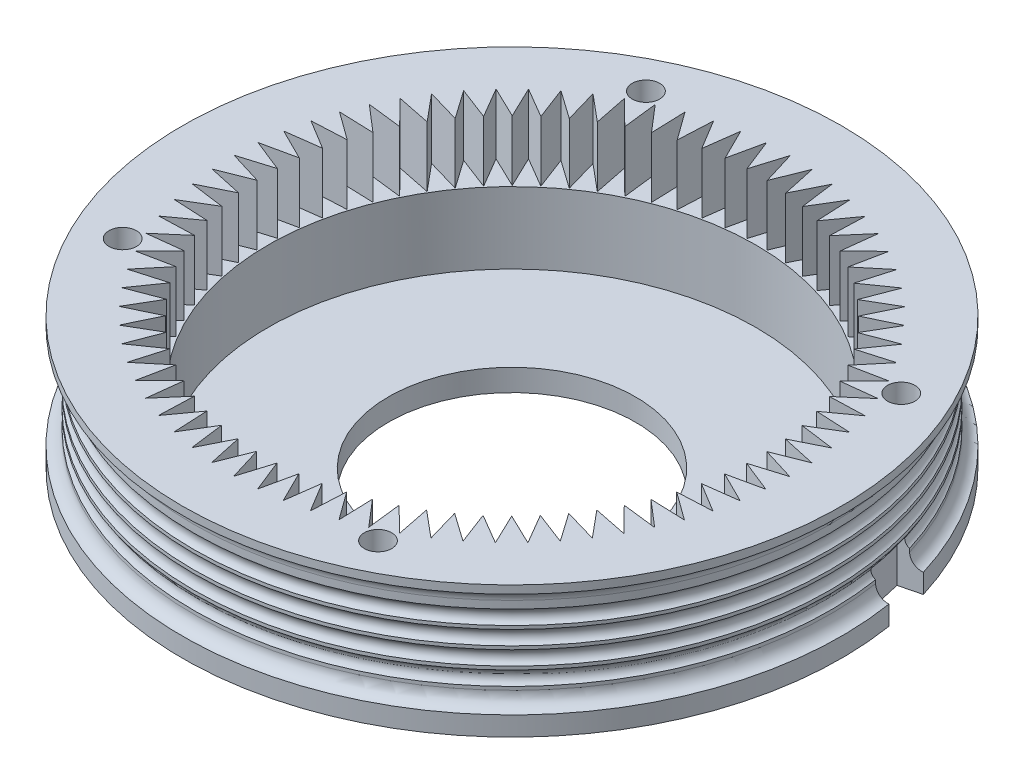
from build123d import *

# Parameters (mm, degrees)
SKETCH1_R           = 23
BOSS_EXTRUDE1_DEPTH = 2
SKETCH2_R           = 30
SKETCH2_R_2         = 22.2
BOSS_EXTRUDE2_DEPTH = 12
SKETCH3_R           = 11.25
CUT_EXTRUDE1_DEPTH  = 10
CUT_EXTRUDE8_DEPTH  = 5.5
SKETCH5_R           = 1.25
CUT_EXTRUDE3_DEPTH  = 45.676615807
SKETCH8_R           = 2.5
CUT_EXTRUDE5_DEPTH  = 2
BOSS_EXTRUDE3_DEPTH = 3
CUT_EXTRUDE9_START  = -3
SKETCH13_R          = 3.5
CUT_EXTRUDE9_DEPTH  = 3
CUT_EXTRUDE10_DEPTH = 4


with BuildPart() as part:
    # Sketch1 → Boss-Extrude1 (new body)
    with BuildSketch(Plane(origin=(0, 0, 0), x_dir=(1, 0, 0), z_dir=(0, 1, 0))):
        Circle(SKETCH1_R)
    extrude(amount=-BOSS_EXTRUDE1_DEPTH)

    # Sketch2 → Boss-Extrude2 (add)
    with BuildSketch(Plane(origin=(0, 0, 0), x_dir=(1, 0, 0), z_dir=(0, 1, 0))):
        Circle(SKETCH2_R)
        Circle(SKETCH2_R_2, mode=Mode.SUBTRACT)
    extrude(amount=BOSS_EXTRUDE2_DEPTH)

    # Sketch3 → Cut-Extrude1 (cut)
    with BuildSketch(Plane(origin=(0, 0, 0), x_dir=(1, 0, 0), z_dir=(0, 1, 0))):
        Circle(SKETCH3_R)
    extrude(amount=-CUT_EXTRUDE1_DEPTH, mode=Mode.SUBTRACT)

    # Sketch10 → Cut-Extrude8 (cut)
    with BuildSketch(Plane(origin=(0, 12, 0), x_dir=(1, 0, 0), z_dir=(0, 1, 0))):
        Polygon((8.200315972, -23.949003355), (8.095646912, -20.796423541), (10.150000757, -23.190028641), (9.785351218, -20.056859988), (12.030350745, -22.272642516), (11.408211652, -19.180287743), (13.828521239, -21.20311166), (12.953142433, -18.172694685), (15.532228911, -19.988742051), (14.409590117, -17.040963696), (17.12983571, -18.637829065), (15.76760569, -15.792825644), (18.610428362, -17.159600809), (17.017912527, -14.43680658), (19.963892917, -15.564155079), (18.151969766, -12.982169489), (21.18098384, -13.862390389), (19.162030646, -11.438851016), (22.253387167, -12.065931515), (20.041195426, -9.817393592), (23.173777294, -10.187050095), (20.78345852, -8.128873414), (23.935867025, -8.238580793), (21.383749518, -6.384824789), (24.534450513, -6.233833631), (21.837967824, -4.597161336), (24.965438827, -4.186503063), (22.143010666, -2.77809461), (25.225887879, -2.110574435), (22.296794293, -0.940050681), (25.314018538, -0.020228443), (22.298268206, 0.904414747), (25.229228782, 2.070255729), (22.147422337, 2.742702106), (24.972097812, 4.146597956), (21.845287117, 4.562254028), (24.544382092, 6.194614714), (21.393926434, 6.350641129), (23.949003355, 8.200315972), (20.796423541, 8.095646912), (23.190028641, 10.150000757), (20.056859988, 9.785351218), (22.272642516, 12.030350745), (19.180287743, 11.408211652), (21.20311166, 13.828521239), (18.172694685, 12.953142433), (19.988742051, 15.532228911), (17.040963696, 14.409590117), (18.637829065, 17.12983571), (15.792825644, 15.76760569), (17.159600809, 18.610428362), (14.43680658, 17.017912527), (15.564155079, 19.963892917), (12.982169489, 18.151969766), (13.862390389, 21.18098384), (11.438851016, 19.162030646), (12.065931515, 22.253387167), (9.817393592, 20.041195426), (10.187050095, 23.173777294), (8.128873414, 20.78345852), (8.238580793, 23.935867025), (6.384824789, 21.383749518), (6.233833631, 24.534450513), (4.597161336, 21.837967824), (4.186503063, 24.965438827), (2.77809461, 22.143010666), (2.110574435, 25.225887879), (0.940050681, 22.296794293), (0.020228443, 25.314018538), (-0.904414747, 22.298268206), (-2.070255729, 25.229228782), (-2.742702106, 22.147422337), (-4.146597956, 24.972097812), (-4.562254028, 21.845287117), (-6.194614714, 24.544382092), (-6.350641129, 21.393926434), (-8.200315972, 23.949003355), (-8.095646912, 20.796423541), (-10.150000757, 23.190028641), (-9.785351218, 20.056859988), (-12.030350745, 22.272642516), (-11.408211652, 19.180287743), (-13.828521239, 21.20311166), (-12.953142433, 18.172694685), (-15.532228911, 19.988742051), (-14.409590117, 17.040963696), (-17.12983571, 18.637829065), (-15.76760569, 15.792825644), (-18.610428362, 17.159600809), (-17.017912527, 14.43680658), (-19.963892917, 15.564155079), (-18.151969766, 12.982169489), (-21.18098384, 13.862390389), (-19.162030646, 11.438851016), (-22.253387167, 12.065931515), (-20.041195426, 9.817393592), (-23.173777294, 10.187050095), (-20.78345852, 8.128873414), (-23.935867025, 8.238580793), (-21.383749518, 6.384824789), (-24.534450513, 6.233833631), (-21.837967824, 4.597161336), (-24.965438827, 4.186503063), (-22.143010666, 2.77809461), (-25.225887879, 2.110574435), (-22.296794293, 0.940050681), (-25.314018538, 0.020228443), (-22.298268206, -0.904414747), (-25.229228782, -2.070255729), (-22.147422337, -2.742702106), (-24.972097812, -4.146597956), (-21.845287117, -4.562254028), (-24.544382092, -6.194614714), (-21.393926434, -6.350641129), (-23.949003355, -8.200315972), (-20.796423541, -8.095646912), (-23.190028641, -10.150000757), (-20.056859988, -9.785351218), (-22.272642516, -12.030350745), (-19.180287743, -11.408211652), (-21.20311166, -13.828521239), (-18.172694685, -12.953142433), (-19.988742051, -15.532228911), (-17.040963696, -14.409590118), (-18.637829065, -17.12983571), (-15.792825644, -15.76760569), (-17.159600809, -18.610428362), (-14.43680658, -17.017912527), (-15.564155079, -19.963892917), (-12.982169489, -18.151969766), (-13.862390389, -21.18098384), (-11.438851016, -19.162030646), (-12.065931515, -22.253387167), (-9.817393592, -20.041195426), (-10.187050095, -23.173777294), (-8.128873414, -20.78345852), (-8.238580793, -23.935867025), (-6.384824789, -21.383749518), (-6.233833631, -24.534450513), (-4.597161336, -21.837967824), (-4.186503063, -24.965438827), (-2.77809461, -22.143010666), (-2.110574435, -25.225887879), (-0.940050681, -22.296794293), (-0.020228443, -25.314018538), (0.904414747, -22.298268206), (2.070255729, -25.229228782), (2.742702106, -22.147422337), (4.146597956, -24.972097812), (4.562254028, -21.845287117), (6.194614714, -24.544382092), (6.350641129, -21.393926434), align=None)
    extrude(amount=-CUT_EXTRUDE8_DEPTH, mode=Mode.SUBTRACT)

    # Sketch5 → Cut-Extrude3 (cut, through all)
    with BuildSketch(Plane(origin=(0, 12, 0), x_dir=(1, 0, 0), z_dir=(0, 1, 0))):
        with Locations((23.816653914, 11.619681422)):
            Circle(SKETCH5_R)
        with Locations((11.619681422, -23.816653914)):
            Circle(SKETCH5_R)
        with Locations((-23.816653914, -11.619681422)):
            Circle(SKETCH5_R)
        with Locations((-11.619681422, 23.816653914)):
            Circle(SKETCH5_R)
    extrude(amount=-CUT_EXTRUDE3_DEPTH, mode=Mode.SUBTRACT)

    # Sketch8 → Cut-Extrude5 (cut)
    with BuildSketch(Plane(origin=(0, 0, 0), x_dir=(-1, 0, 0), z_dir=(0, -1, 0))):
        with Locations((-23.816653914, 11.619681422)):
            Circle(SKETCH8_R)
        with Locations((11.619681422, 23.816653914)):
            Circle(SKETCH8_R)
        with Locations((23.816653914, -11.619681422)):
            Circle(SKETCH8_R)
        with Locations((-11.619681422, -23.816653914)):
            Circle(SKETCH8_R)
    extrude(amount=-CUT_EXTRUDE5_DEPTH, mode=Mode.SUBTRACT)

    # Sketch6 → Cut-Revolve1 (revolve, cut)
    with BuildSketch(Plane(origin=(0, 0, 0), x_dir=(0, 0, -1), z_dir=(1, 0, 0))):
        with BuildLine():
            Line((30.052591235, 11.269978745), (30.611201465, 11.269978745))
            Line((30.611201465, 11.269978745), (30.611201465, 1.744054661))
            Line((30.611201465, 1.744054661), (30.052591235, 1.744054661))
            ThreePointArc((30.052591235, 1.744054661), (29.280418603, 2.14822719), (28.97105922, 2.963029485))
            Line((28.97105922, 2.963029485), (28.97105922, 3.270113549))
            ThreePointArc((28.97105922, 3.270113549), (28.601311894, 3.916571517), (28.97105922, 4.563029485))
            Line((28.97105922, 4.563029485), (28.97105922, 4.870113549))
            ThreePointArc((28.97105922, 4.870113549), (28.601311894, 5.516571517), (28.97105922, 6.163029485))
            Line((28.97105922, 6.163029485), (28.97105922, 6.470113549))
            ThreePointArc((28.97105922, 6.470113549), (28.601311894, 7.116571517), (28.97105922, 7.763029485))
            Line((28.97105922, 7.763029485), (28.97105922, 8.070113549))
            ThreePointArc((28.97105922, 8.070113549), (28.601311894, 8.716571517), (28.97105922, 9.363029485))
            Line((28.97105922, 9.363029485), (28.97105922, 9.670113549))
            Line((28.97105922, 9.670113549), (28.97105922, 10.051003921))
            ThreePointArc((28.97105922, 10.051003921), (29.280418603, 10.865806216), (30.052591235, 11.269978745))
        make_face()
    revolve(axis=Axis((0, -2, 0), (0, 1, 0)), mode=Mode.SUBTRACT)

    # Sketch12 → Boss-Extrude3 (add)
    with BuildSketch(Plane(origin=(0, -2, 0), x_dir=(-1, 0, 0), z_dir=(0, -1, 0))):
        with BuildLine():
            ThreePointArc((-19.196569326, 5.50814394), (-12.700037344, 3.137602549), (-19.610339715, 3.406145686))
            Line((-19.610339715, 3.406145686), (-22.604401204, 3.986816711))
            ThreePointArc((-22.604401204, 3.986816711), (-22.945534904, 0.596732148), (-22.781071358, -2.806501209))
            Line((-22.781071358, -2.806501209), (-13.282801681, -1.913655237))
            Line((-13.282801681, -1.913655237), (-11.151246895, 7.8263568))
            Line((-11.151246895, 7.8263568), (-19.244527438, 12.510068943))
            ThreePointArc((-19.244527438, 12.510068943), (-20.891029647, 9.50886647), (-22.072877276, 6.296169473))
            Line((-22.072877276, 6.296169473), (-19.196569326, 5.50814394))
        make_face()
    extrude(amount=BOSS_EXTRUDE3_DEPTH)

    # Sketch13 → Cut-Extrude9 (cut)
    with BuildSketch(Plane(origin=(0, -2, 0), x_dir=(-1, 0, 0), z_dir=(0, -1, 0)).offset(CUT_EXTRUDE9_START)):
        with Locations((-16.134136684, 3.813591988)):
            Circle(SKETCH13_R)
    extrude(amount=CUT_EXTRUDE9_DEPTH, mode=Mode.SUBTRACT)

    # Sketch15 → Cut-Extrude10 (cut)
    with BuildSketch(Plane(origin=(0, 0, 0), x_dir=(-1, 0, 0), z_dir=(0, -1, 0))):
        Polygon((-27.685056753, 4.305602049), (-29.062732762, 4.572679608), (-29.895458244, 4.734112549), (-29.095069333, 8.862788139), (-28.130605106, 8.620305944), (-26.766064483, 8.277237952), align=None)
    extrude(amount=-CUT_EXTRUDE10_DEPTH, mode=Mode.SUBTRACT)


solid = part.part
